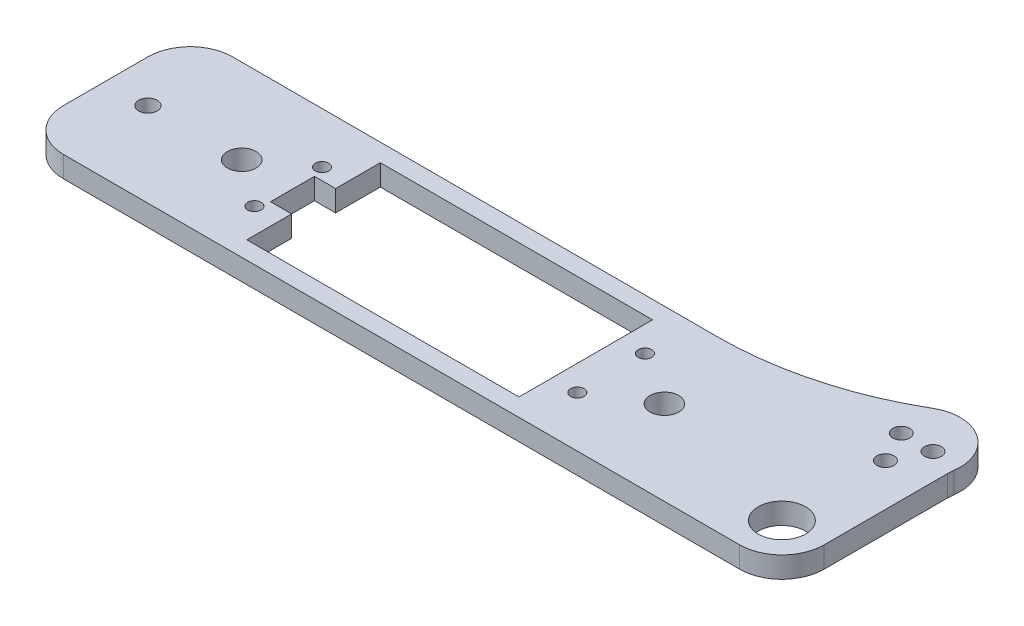
from build123d import *

# Parameters (mm, degrees)
SKETCH1_R           = 2.159
SKETCH1_R_2         = 1.016
SKETCH1_R_3         = 1.27
SKETCH1_R_4         = 3.556
SKETCH1_R_5         = 1.397
BOSS_EXTRUDE1_DEPTH = 3.175


with BuildPart() as part:
    # Sketch1 → Boss-Extrude1 (new body)
    with BuildSketch(Plane.XZ.offset(3.175)):
        with BuildLine():
            Line((57.15, -12.178356694), (57.15, 6.35))
            ThreePointArc((57.15, 6.35), (55.290128061, 10.840128061), (50.8, 12.7))
            Line((50.8, 12.7), (-50.8, 12.7))
            ThreePointArc((-50.8, 12.7), (-55.290128061, 10.840128061), (-57.15, 6.35))
            Line((-57.15, 6.35), (-57.15, -6.35))
            ThreePointArc((-57.15, -6.35), (-55.290128061, -10.840128061), (-50.8, -12.7))
            Line((-50.8, -12.7), (22.037329994, -12.7))
            ThreePointArc((22.037329994, -12.7), (35.247097555, -14.447558257), (47.548013212, -19.569998386))
            ThreePointArc((47.548013212, -19.569998386), (54.415840096, -19.342252823), (57.212260887, -13.065394938))
            ThreePointArc((57.212260887, -13.065394938), (57.165584345, -12.622966991), (57.15, -12.178356694))
        make_face()
        with Locations(Location((26.797, 0, 0), (0, 0, 90))):  # turned: the seam where the file's is
            Circle(SKETCH1_R, mode=Mode.SUBTRACT)
        with Locations(Location((-36.703, 0, 0), (0, 0, 90))):  # turned: the seam where the file's is
            Circle(SKETCH1_R, mode=Mode.SUBTRACT)
        with Locations(Location((-29.718, -5.08, 0), (0, 0, 90))):  # turned: the seam where the file's is
            Circle(SKETCH1_R_2, mode=Mode.SUBTRACT)
        with Locations(Location((18.796, -5.08, 0), (0, 0, 90))):  # turned: the seam where the file's is
            Circle(SKETCH1_R_2, mode=Mode.SUBTRACT)
        with Locations(Location((18.796, 5.08, 0), (0, 0, 90))):  # turned: the seam where the file's is
            Circle(SKETCH1_R_2, mode=Mode.SUBTRACT)
        with Locations(Location((-29.718, 5.08, 0), (0, 0, 90))):  # turned: the seam where the file's is
            Circle(SKETCH1_R_2, mode=Mode.SUBTRACT)
        with Locations(Location((50.8, -9.2075, 0), (0, 0, 90))):  # turned: the seam where the file's is
            Circle(SKETCH1_R_3, mode=Mode.SUBTRACT)
        with Locations(Location((48.41875, -13.97, 0), (0, 0, 90))):  # turned: the seam where the file's is
            Circle(SKETCH1_R_3, mode=Mode.SUBTRACT)
        with Locations(Location((53.18125, -13.97, 0), (0, 0, 90))):  # turned: the seam where the file's is
            Circle(SKETCH1_R_3, mode=Mode.SUBTRACT)
        with Locations(Location((50.8, 6.35, 0), (0, 0, 90))):  # turned: the seam where the file's is
            Circle(SKETCH1_R_4, mode=Mode.SUBTRACT)
        with Locations(Location((-50.8, 0, 0), (0, 0, 90))):  # turned: the seam where the file's is
            Circle(SKETCH1_R_5, mode=Mode.SUBTRACT)
        Polygon((-25.908, 10.033), (14.986, 10.033), (14.986, -10.033), (-25.908, -10.033), (-25.908, -3.302), (-29.083, -3.302), (-29.083, 3.302), (-25.908, 3.302), align=None, mode=Mode.SUBTRACT)
    extrude(amount=-BOSS_EXTRUDE1_DEPTH)


solid = part.part
